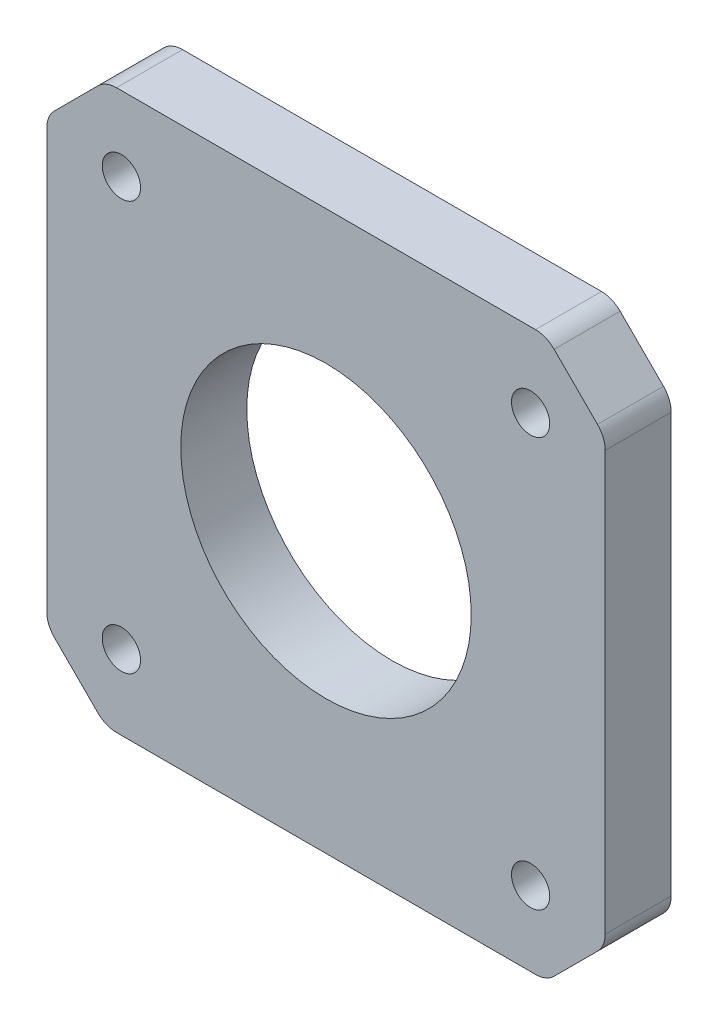
from build123d import *

# Parameters (mm, degrees)
SKETCH1_R           = 1.45
SKETCH1_R_2         = 11
BOSS_EXTRUDE1_DEPTH = 5


with BuildPart() as part:
    # Sketch1 → Boss-Extrude1 (new body)
    with BuildSketch(Plane.XY):
        with BuildLine():
            Line((-20.564213562, -17.28137085), (-17.28137085, -20.564213562))
            ThreePointArc((-17.28137085, -20.564213562), (-16.632524152, -20.997759065), (-15.867157288, -21.15))
            Line((-15.867157288, -21.15), (15.867157288, -21.15))
            ThreePointArc((15.867157288, -21.15), (16.632524152, -20.997759065), (17.28137085, -20.564213562))
            Line((17.28137085, -20.564213562), (20.564213562, -17.28137085))
            ThreePointArc((20.564213562, -17.28137085), (20.997759065, -16.632524152), (21.15, -15.867157288))
            Line((21.15, -15.867157288), (21.15, 15.867157288))
            ThreePointArc((21.15, 15.867157288), (20.997759065, 16.632524152), (20.564213562, 17.28137085))
            Line((20.564213562, 17.28137085), (17.28137085, 20.564213562))
            ThreePointArc((17.28137085, 20.564213562), (16.632524152, 20.997759065), (15.867157288, 21.15))
            Line((15.867157288, 21.15), (-15.867157288, 21.15))
            ThreePointArc((-15.867157288, 21.15), (-16.632524152, 20.997759065), (-17.28137085, 20.564213562))
            Line((-17.28137085, 20.564213562), (-20.564213562, 17.28137085))
            ThreePointArc((-20.564213562, 17.28137085), (-20.997759065, 16.632524152), (-21.15, 15.867157288))
            Line((-21.15, 15.867157288), (-21.15, -15.867157288))
            ThreePointArc((-21.15, -15.867157288), (-20.997759065, -16.632524152), (-20.564213562, -17.28137085))
        make_face()
        with Locations((-15.5, 15.5)):
            Circle(SKETCH1_R, mode=Mode.SUBTRACT)
        with Locations((15.5, 15.5)):
            Circle(SKETCH1_R, mode=Mode.SUBTRACT)
        with Locations((15.5, -15.5)):
            Circle(SKETCH1_R, mode=Mode.SUBTRACT)
        with Locations((-15.5, -15.5)):
            Circle(SKETCH1_R, mode=Mode.SUBTRACT)
        Circle(SKETCH1_R_2, mode=Mode.SUBTRACT)
    extrude(amount=BOSS_EXTRUDE1_DEPTH)


solid = part.part
